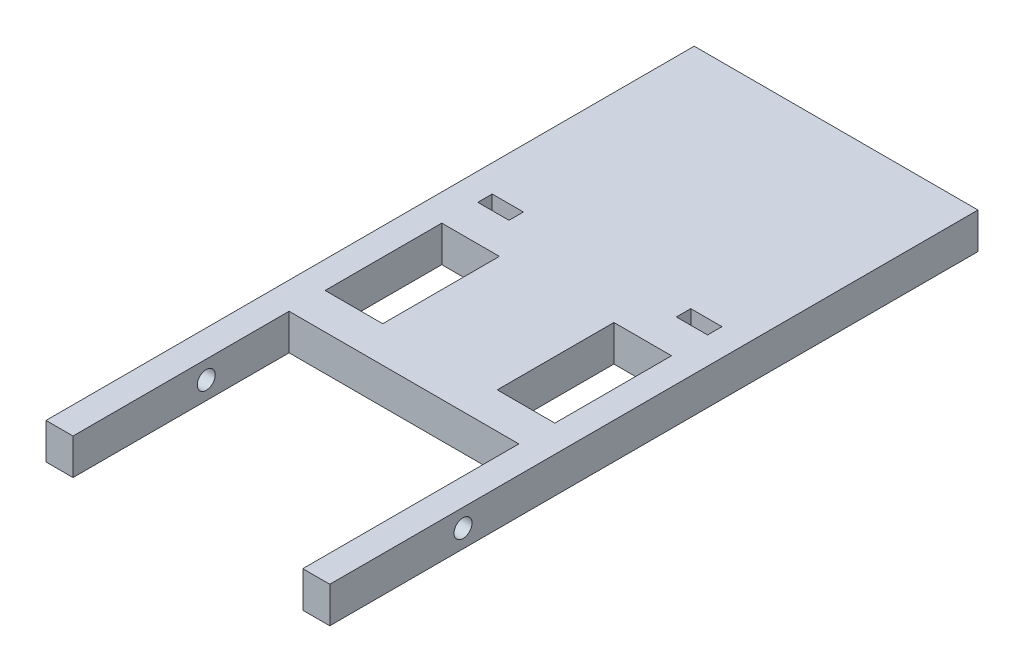
from build123d import *

# Parameters (mm, degrees)
SKETCH1_W               = 100.076
SKETCH1_H               = 228.6
BOSS_EXTRUDE1_DEPTH     = 12.7
SKETCH2_W               = 81.026
SKETCH2_H               = 76.2
CUT_EXTRUDE1_DEPTH      = 13.7
SKETCH3_W               = 20.32
SKETCH3_H               = 41.148
SKETCH3_W_2             = 10.9982
SKETCH3_H_2             = 5.08
CUT_EXTRUDE2_DEPTH      = 13.7
SKETCH4_R               = 3.175
CUT_EXTRUDE3_DEPTH      = 91.551
CUT_EXTRUDE3_DEPTH_BACK = 10.525


with BuildPart() as part:
    # Sketch1 → Boss-Extrude1 (new body)
    with BuildSketch(Plane(origin=(0, 0, 0), x_dir=(1, 0, 0), z_dir=(0, 1, 0))):
        Rectangle(SKETCH1_W, SKETCH1_H)
    extrude(amount=BOSS_EXTRUDE1_DEPTH)

    # Sketch2 → Cut-Extrude1 (cut, through all)
    with BuildSketch(Plane(origin=(0, 12.7, 0), x_dir=(1, 0, 0), z_dir=(0, 1, 0))):
        with Locations((0, -76.2)):
            Rectangle(SKETCH2_W, SKETCH2_H)
    extrude(amount=-CUT_EXTRUDE1_DEPTH, mode=Mode.SUBTRACT)

    # Sketch3 → Cut-Extrude2 (cut, through all)
    with BuildSketch(Plane(origin=(0, 12.7, 0), x_dir=(1, 0, 0), z_dir=(0, 1, 0))):
        with Locations((-30.353, -4.826)):
            Rectangle(SKETCH3_W, SKETCH3_H)
        with Locations((-35.0139, 30.988)):
            Rectangle(SKETCH3_W_2, SKETCH3_H_2)
        with Locations((30.353, -4.826)):
            Rectangle(SKETCH3_W, SKETCH3_H)
        with Locations((35.0139, 30.988)):
            Rectangle(SKETCH3_W_2, SKETCH3_H_2)
    extrude(amount=-CUT_EXTRUDE2_DEPTH, mode=Mode.SUBTRACT)

    # Sketch4 → Cut-Extrude3 (cut, two sides)
    with BuildSketch(Plane(origin=(-40.513, 0, 0), x_dir=(0, 0, -1), z_dir=(1, 0, 0))) as cut_extrude3_sk:
        with Locations((-67.31, 6.35)):
            Circle(SKETCH4_R)
    extrude(amount=CUT_EXTRUDE3_DEPTH, mode=Mode.SUBTRACT)
    extrude(cut_extrude3_sk.sketch, amount=-CUT_EXTRUDE3_DEPTH_BACK, mode=Mode.SUBTRACT)


solid = part.part
